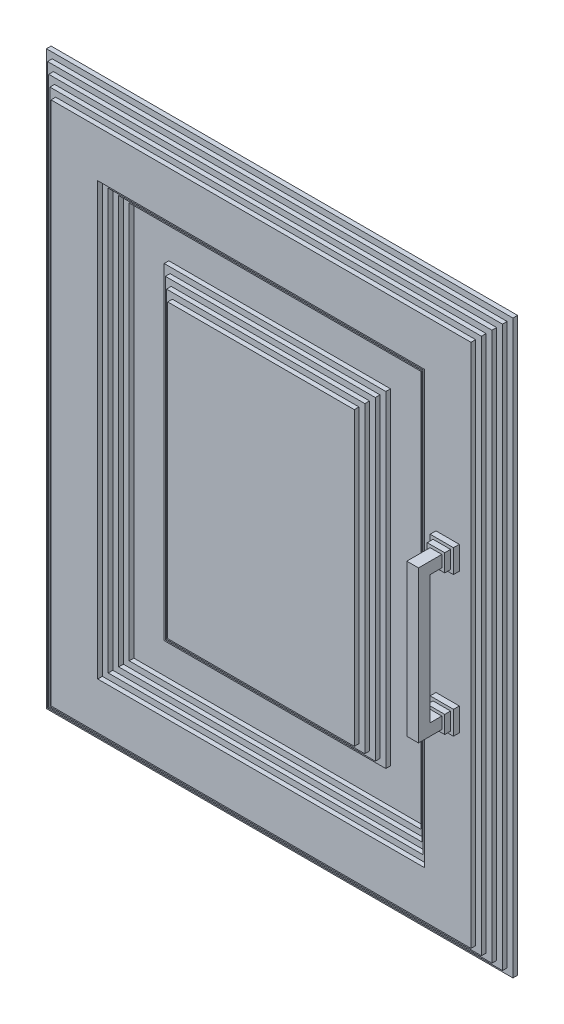
from build123d import *

# Parameters (mm, degrees)
BOSS_EXTRUDE2_DEPTH  = 4
SKETCH2_W            = 390
SKETCH2_H            = 480
BOSS_EXTRUDE3_DEPTH  = 4
SKETCH3_W            = 380
SKETCH3_H            = 470
BOSS_EXTRUDE4_DEPTH  = 4
SKETCH4_W            = 370
SKETCH4_H            = 460
BOSS_EXTRUDE5_DEPTH  = 4
SKETCH5_W            = 360
SKETCH5_H            = 450
BOSS_EXTRUDE6_DEPTH  = 4
SKETCH6_W            = 280
SKETCH6_H            = 370
CUT_EXTRUDE1_DEPTH   = 4
SKETCH7_W            = 270
SKETCH7_H            = 360
CUT_EXTRUDE2_DEPTH   = 4
SKETCH8_W            = 260
SKETCH8_H            = 350
CUT_EXTRUDE3_DEPTH   = 4
SKETCH9_W            = 250
SKETCH9_H            = 340
CUT_EXTRUDE4_DEPTH   = 4
SKETCH11_W           = 190
SKETCH11_H           = 280
BOSS_EXTRUDE7_DEPTH  = 4
SKETCH12_W           = 180
SKETCH12_H           = 270
BOSS_EXTRUDE8_DEPTH  = 4
SKETCH13_W           = 170
SKETCH13_H           = 260
BOSS_EXTRUDE9_DEPTH  = 4
SKETCH14_W           = 160
SKETCH14_H           = 250
BOSS_EXTRUDE10_DEPTH = 4
SKETCH15_W           = 20
SKETCH15_H           = 20
BOSS_EXTRUDE11_DEPTH = 5
SKETCH16_W           = 15
SKETCH16_H           = 15
BOSS_EXTRUDE12_DEPTH = 5
SKETCH17_W           = 10
SKETCH17_H           = 10
BOSS_EXTRUDE13_DEPTH = 20
BOSS_EXTRUDE14_REACH = 302
SKETCH18_W           = 10
SKETCH18_H           = 10
SKETCH19_W           = 35
SKETCH19_H           = 50
CUT_EXTRUDE5_DEPTH   = 3


with BuildPart() as part:
    # Sketch1 → Boss-Extrude2 (new body)
    with BuildSketch(Plane.XY):
        Polygon((200, 0), (200, -20), (200, -245), (-200, -245), (-200, -20), (-200, 0), (-200, 245), (200, 245), align=None)
    extrude(amount=BOSS_EXTRUDE2_DEPTH)

    # Sketch2 → Boss-Extrude3 (add)
    with BuildSketch(Plane.XY.offset(4)):
        Rectangle(SKETCH2_W, SKETCH2_H)
    extrude(amount=BOSS_EXTRUDE3_DEPTH)

    # Sketch3 → Boss-Extrude4 (add)
    with BuildSketch(Plane.XY.offset(8)):
        Rectangle(SKETCH3_W, SKETCH3_H)
    extrude(amount=BOSS_EXTRUDE4_DEPTH)

    # Sketch4 → Boss-Extrude5 (add)
    with BuildSketch(Plane.XY.offset(12)):
        Rectangle(SKETCH4_W, SKETCH4_H)
    extrude(amount=BOSS_EXTRUDE5_DEPTH)

    # Sketch5 → Boss-Extrude6 (add)
    with BuildSketch(Plane.XY.offset(16)):
        Rectangle(SKETCH5_W, SKETCH5_H)
    extrude(amount=BOSS_EXTRUDE6_DEPTH)

    # Sketch6 → Cut-Extrude1 (cut)
    with BuildSketch(Plane.XY.offset(20)):
        Rectangle(SKETCH6_W, SKETCH6_H)
    extrude(amount=-CUT_EXTRUDE1_DEPTH, mode=Mode.SUBTRACT)

    # Sketch7 → Cut-Extrude2 (cut)
    with BuildSketch(Plane.XY.offset(16)):
        Rectangle(SKETCH7_W, SKETCH7_H)
    extrude(amount=-CUT_EXTRUDE2_DEPTH, mode=Mode.SUBTRACT)

    # Sketch8 → Cut-Extrude3 (cut)
    with BuildSketch(Plane.XY.offset(12)):
        Rectangle(SKETCH8_W, SKETCH8_H)
    extrude(amount=-CUT_EXTRUDE3_DEPTH, mode=Mode.SUBTRACT)

    # Sketch9 → Cut-Extrude4 (cut)
    with BuildSketch(Plane.XY.offset(8)):
        Rectangle(SKETCH9_W, SKETCH9_H)
    extrude(amount=-CUT_EXTRUDE4_DEPTH, mode=Mode.SUBTRACT)

    # Sketch11 → Boss-Extrude7 (add)
    with BuildSketch(Plane.XY.offset(4)):
        Rectangle(SKETCH11_W, SKETCH11_H)
    extrude(amount=BOSS_EXTRUDE7_DEPTH)

    # Sketch12 → Boss-Extrude8 (add)
    with BuildSketch(Plane.XY.offset(8)):
        Rectangle(SKETCH12_W, SKETCH12_H)
    extrude(amount=BOSS_EXTRUDE8_DEPTH)

    # Sketch13 → Boss-Extrude9 (add)
    with BuildSketch(Plane.XY.offset(12)):
        Rectangle(SKETCH13_W, SKETCH13_H)
    extrude(amount=BOSS_EXTRUDE9_DEPTH)

    # Sketch14 → Boss-Extrude10 (add)
    with BuildSketch(Plane.XY.offset(16)):
        Rectangle(SKETCH14_W, SKETCH14_H)
    extrude(amount=BOSS_EXTRUDE10_DEPTH)

    # Sketch15 → Boss-Extrude11 (add)
    with BuildSketch(Plane.XY.offset(20)):
        with Locations((160, 60)):
            Rectangle(SKETCH15_W, SKETCH15_H)
        with Locations((160, -60)):
            Rectangle(SKETCH15_W, SKETCH15_H)
    extrude(amount=BOSS_EXTRUDE11_DEPTH)

    # Sketch16 → Boss-Extrude12 (add)
    with BuildSketch(Plane.XY.offset(25)):
        with Locations((160, 60)):
            Rectangle(SKETCH16_W, SKETCH16_H)
        with Locations((160, -60)):
            Rectangle(SKETCH16_W, SKETCH16_H)
    extrude(amount=BOSS_EXTRUDE12_DEPTH)

    # Sketch17 → Boss-Extrude13 (add)
    with BuildSketch(Plane.XY.offset(30)):
        with Locations((160, 60)):
            Rectangle(SKETCH17_W, SKETCH17_H)
        with Locations((160, -60)):
            Rectangle(SKETCH17_W, SKETCH17_H)
    extrude(amount=BOSS_EXTRUDE13_DEPTH)

    # Sketch18 → Boss-Extrude14 (add, up to next)
    with BuildSketch(Plane.XZ.offset(-55), mode=Mode.PRIVATE) as boss_extrude14_sk1:
        with Locations((160, 45)):
            Rectangle(SKETCH18_W, SKETCH18_H)
    boss_extrude14_tool1 = extrude(boss_extrude14_sk1.sketch, amount=BOSS_EXTRUDE14_REACH, mode=Mode.PRIVATE) - part.part
    add(boss_extrude14_tool1.solids().sort_by_distance((160, 55, 45))[0])

    # Sketch19 → Cut-Extrude5 (cut)
    with BuildSketch(Plane(origin=(0, 0, 0), x_dir=(-1, 0, 0), z_dir=(0, 0, -1))):
        with Locations((182.5, 125)):
            Rectangle(SKETCH19_W, SKETCH19_H)
        with Locations((182.5, -175)):
            Rectangle(SKETCH19_W, SKETCH19_H)
    extrude(amount=-CUT_EXTRUDE5_DEPTH, mode=Mode.SUBTRACT)


solid = part.part
